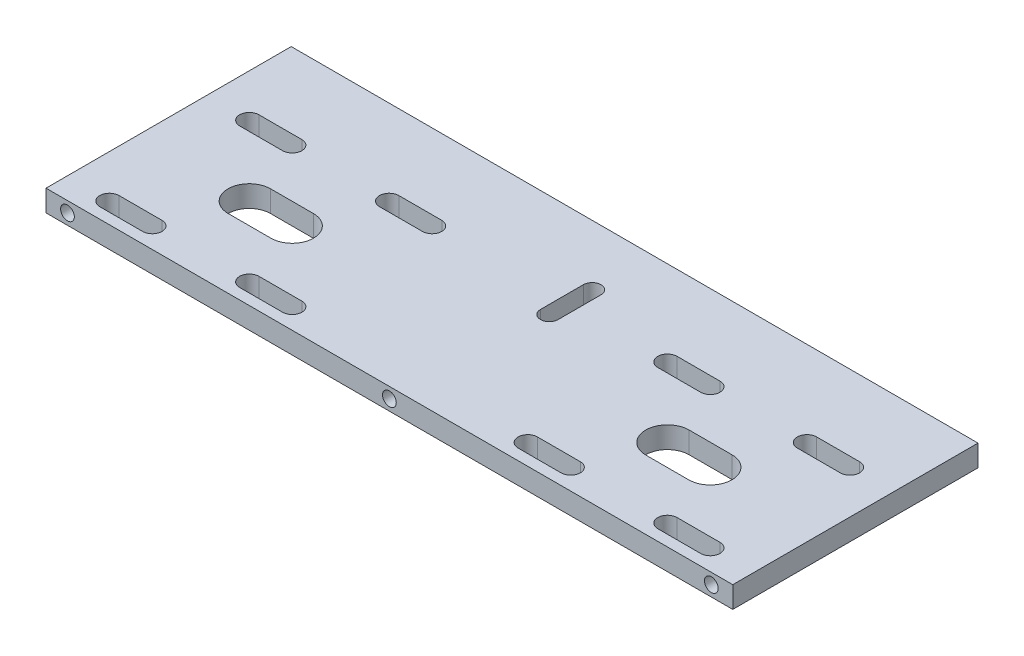
from build123d import *

# Parameters (mm, degrees)
SKETCH1_W           = 159.999999944
SKETCH1_H           = 42.132527592
BOSS_EXTRUDE1_DEPTH = 5
SKETCH4_R           = 1.6
CUT_EXTRUDE2_DEPTH  = 10
CUT_EXTRUDE4_DEPTH  = 6
SKETCH10_W          = 160
SKETCH10_H          = 10
BOSS_EXTRUDE4_DEPTH = 5
CUT_EXTRUDE5_DEPTH  = 6
SKETCH11_W          = 160
SKETCH11_H          = 5
BOSS_EXTRUDE5_DEPTH = 5


with BuildPart() as part:
    # Sketch1 → Boss-Extrude1 (new body)
    with BuildSketch(Plane(origin=(0, 0, 0), x_dir=(1, 0, 0), z_dir=(0, 1, 0))):
        Rectangle(SKETCH1_W, SKETCH1_H)
        with BuildLine():
            Line((-69.999999972, 18.546018972), (-59.999999972, 18.546018972))
            ThreePointArc((-59.999999972, 18.546018972), (-57.749999972, 16.296018972), (-59.999999972, 14.046018972))
            Line((-59.999999972, 14.046018972), (-69.999999972, 14.046018972))
            ThreePointArc((-69.999999972, 14.046018972), (-72.249999972, 16.296018972), (-69.999999972, 18.546018972))
        make_face(mode=Mode.SUBTRACT)
        with BuildLine():
            Line((-37.407962028, 18.546018972), (-27.407962028, 18.546018972))
            ThreePointArc((-27.407962028, 18.546018972), (-25.157962028, 16.296018972), (-27.407962028, 14.046018972))
            Line((-27.407962028, 14.046018972), (-37.407962028, 14.046018972))
            ThreePointArc((-37.407962028, 14.046018972), (-39.657962028, 16.296018972), (-37.407962028, 18.546018972))
        make_face(mode=Mode.SUBTRACT)
        with BuildLine():
            Line((-69.999999972, -18.546018972), (-59.999999972, -18.546018972))
            ThreePointArc((-59.999999972, -18.546018972), (-57.749999972, -16.296018972), (-59.999999972, -14.046018972))
            Line((-59.999999972, -14.046018972), (-69.999999972, -14.046018972))
            ThreePointArc((-69.999999972, -14.046018972), (-72.249999972, -16.296018972), (-69.999999972, -18.546018972))
        make_face(mode=Mode.SUBTRACT)
        with BuildLine():
            Line((-37.407962028, -18.546018972), (-27.407962028, -18.546018972))
            ThreePointArc((-27.407962028, -18.546018972), (-25.157962028, -16.296018972), (-27.407962028, -14.046018972))
            Line((-27.407962028, -14.046018972), (-37.407962028, -14.046018972))
            ThreePointArc((-37.407962028, -14.046018972), (-39.657962028, -16.296018972), (-37.407962028, -18.546018972))
        make_face(mode=Mode.SUBTRACT)
        with BuildLine():
            Line((-53.703981, 4.964699858), (-43.703981, 4.964699858))
            ThreePointArc((-43.703981, 4.964699858), (-38.739281142, 0), (-43.703981, -4.964699858))
            Line((-43.703981, -4.964699858), (-53.703981, -4.964699858))
            ThreePointArc((-53.703981, -4.964699858), (-58.668680858, 0), (-53.703981, 4.964699858))
        make_face(mode=Mode.SUBTRACT)
        with BuildLine():
            Line((37.440525033, 14.013455967), (27.440525033, 14.013455967))
            ThreePointArc((27.440525033, 14.013455967), (25.190525033, 16.263455967), (27.440525033, 18.513455967))
            Line((27.440525033, 18.513455967), (37.440525033, 18.513455967))
            ThreePointArc((37.440525033, 18.513455967), (39.690525033, 16.263455967), (37.440525033, 14.013455967))
        make_face(mode=Mode.SUBTRACT)
        with BuildLine():
            Line((69.967436967, 14.013455967), (59.967436967, 14.013455967))
            ThreePointArc((59.967436967, 14.013455967), (57.717436967, 16.263455967), (59.967436967, 18.513455967))
            Line((59.967436967, 18.513455967), (69.967436967, 18.513455967))
            ThreePointArc((69.967436967, 18.513455967), (72.217436967, 16.263455967), (69.967436967, 14.013455967))
        make_face(mode=Mode.SUBTRACT)
        with BuildLine():
            Line((53.703981, -5.050207727), (43.703981, -5.050207727))
            ThreePointArc((43.703981, -5.050207727), (38.653773273, 0), (43.703981, 5.050207727))
            Line((43.703981, 5.050207727), (53.703981, 5.050207727))
            ThreePointArc((53.703981, 5.050207727), (58.754188727, 0), (53.703981, -5.050207727))
        make_face(mode=Mode.SUBTRACT)
        with BuildLine():
            Line((37.440525033, -14.013455967), (27.440525033, -14.013455967))
            ThreePointArc((27.440525033, -14.013455967), (25.190525033, -16.263455967), (27.440525033, -18.513455967))
            Line((27.440525033, -18.513455967), (37.440525033, -18.513455967))
            ThreePointArc((37.440525033, -18.513455967), (39.690525033, -16.263455967), (37.440525033, -14.013455967))
        make_face(mode=Mode.SUBTRACT)
        with BuildLine():
            Line((69.967436967, -14.013455967), (59.967436967, -14.013455967))
            ThreePointArc((59.967436967, -14.013455967), (57.717436967, -16.263455967), (59.967436967, -18.513455967))
            Line((59.967436967, -18.513455967), (69.967436967, -18.513455967))
            ThreePointArc((69.967436967, -18.513455967), (72.217436967, -16.263455967), (69.967436967, -14.013455967))
        make_face(mode=Mode.SUBTRACT)
    extrude(amount=BOSS_EXTRUDE1_DEPTH)

    # Sketch4 → Cut-Extrude2 (cut)
    with BuildSketch(Plane.XY.offset(21.066263796)):
        with Locations((-74.999999972, 2.5)):
            Circle(SKETCH4_R)
        with Locations((74.999999972, 2.5)):
            Circle(SKETCH4_R)
        with Locations((0, 2.5)):
            Circle(SKETCH4_R)
    extrude(amount=-CUT_EXTRUDE2_DEPTH, mode=Mode.SUBTRACT)

    # Sketch9 → Cut-Extrude4 (cut, through all)
    with BuildSketch(Plane.XZ):
        with BuildLine():
            Line((2.070498026, -22.066263796), (2.070498026, -12.066263796))
            ThreePointArc((2.070498026, -12.066263796), (4.120498026, -10.016263796), (6.170498026, -12.066263796))
            Line((6.170498026, -12.066263796), (6.170498026, -22.066263796))
            ThreePointArc((6.170498026, -22.066263796), (4.120498026, -24.116263796), (2.070498026, -22.066263796))
        make_face()
    extrude(amount=-CUT_EXTRUDE4_DEPTH, mode=Mode.SUBTRACT)

    # Sketch10 → Boss-Extrude4 (add)
    with BuildSketch(Plane(origin=(0, 5, 0), x_dir=(1, 0, 0), z_dir=(0, 1, 0))):
        with Locations((2.8e-08, 26.066263796)):
            Rectangle(SKETCH10_W, SKETCH10_H)
    extrude(amount=-BOSS_EXTRUDE4_DEPTH)

    # Sketch9_2 → Cut-Extrude5 (cut, through all)
    with BuildSketch(Plane.XZ):
        with BuildLine():
            Line((2.070498026, -22.066263796), (2.070498026, -12.066263796))
            ThreePointArc((2.070498026, -12.066263796), (4.120498026, -10.016263796), (6.170498026, -12.066263796))
            Line((6.170498026, -12.066263796), (6.170498026, -22.066263796))
            ThreePointArc((6.170498026, -22.066263796), (4.120498026, -24.116263796), (2.070498026, -22.066263796))
        make_face()
    extrude(amount=-CUT_EXTRUDE5_DEPTH, mode=Mode.SUBTRACT)

    # Sketch11 → Boss-Extrude5 (add)
    with BuildSketch(Plane(origin=(0, 5, 0), x_dir=(1, 0, 0), z_dir=(0, 1, 0))):
        with Locations((2.8e-08, 33.566263796)):
            Rectangle(SKETCH11_W, SKETCH11_H)
    extrude(amount=-BOSS_EXTRUDE5_DEPTH)


solid = part.part
